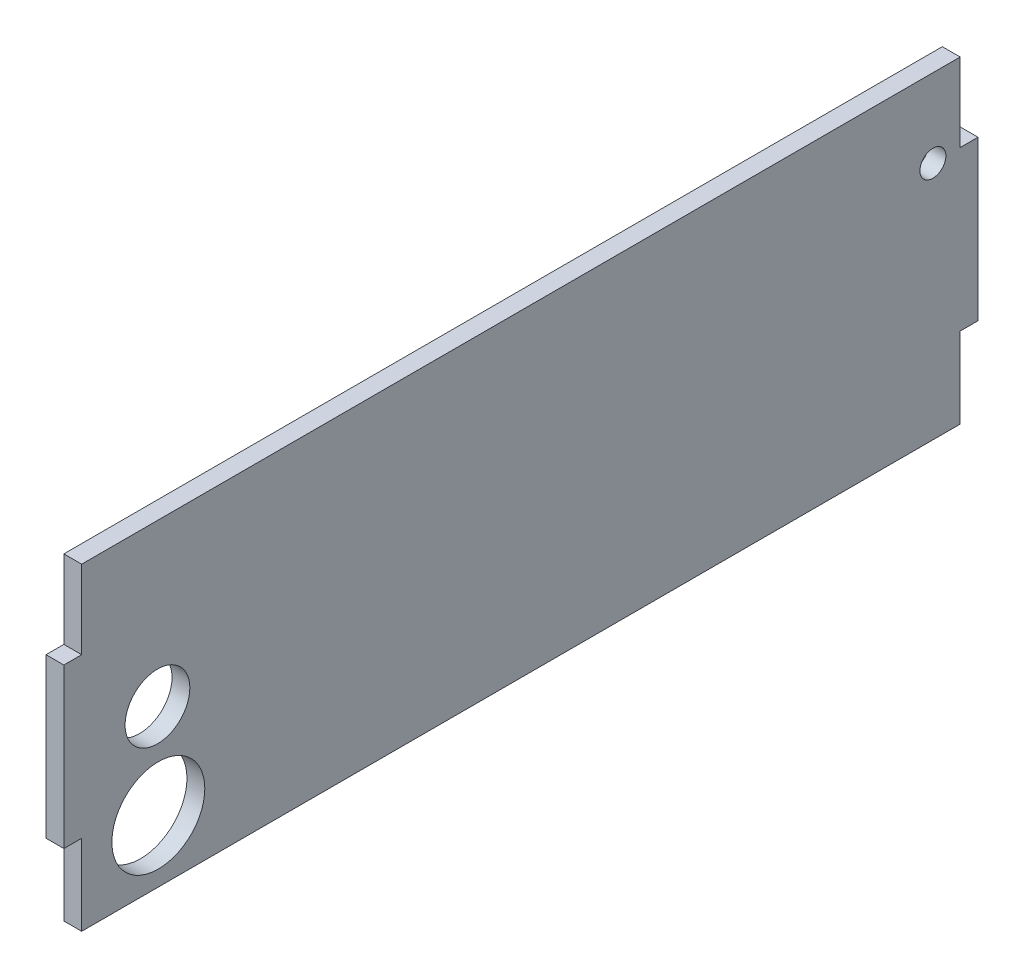
from build123d import *

# Parameters (mm, degrees)
SKETCH1_R           = 4.15
SKETCH1_R_2         = 10.345352818
SKETCH1_R_3         = 14.85
BOSS_EXTRUDE1_DEPTH = 5.7


with BuildPart() as part:
    # Sketch1 → Boss-Extrude1 (new body)
    with BuildSketch(Plane(origin=(0, 0, 0), x_dir=(0, 0, -1), z_dir=(1, 0, 0))):
        Polygon((-140.35, 50.8), (140.35, 50.8), (140.35, 25.75), (146.05, 25.75), (146.05, -25.05), (140.35, -25.05), (140.35, -50.8), (-140.35, -50.8), (-140.35, -25.05), (-146.05, -25.05), (-146.05, 25.75), (-140.35, 25.75), align=None)
        with Locations((131.642431314, 25.75)):
            Circle(SKETCH1_R, mode=Mode.SUBTRACT)
        with Locations((-116.133665793, -0.68799565)):
            Circle(SKETCH1_R_2, mode=Mode.SUBTRACT)
        with Locations((-115.858467533, -30.959804269)):
            Circle(SKETCH1_R_3, mode=Mode.SUBTRACT)
    extrude(amount=BOSS_EXTRUDE1_DEPTH)


solid = part.part
